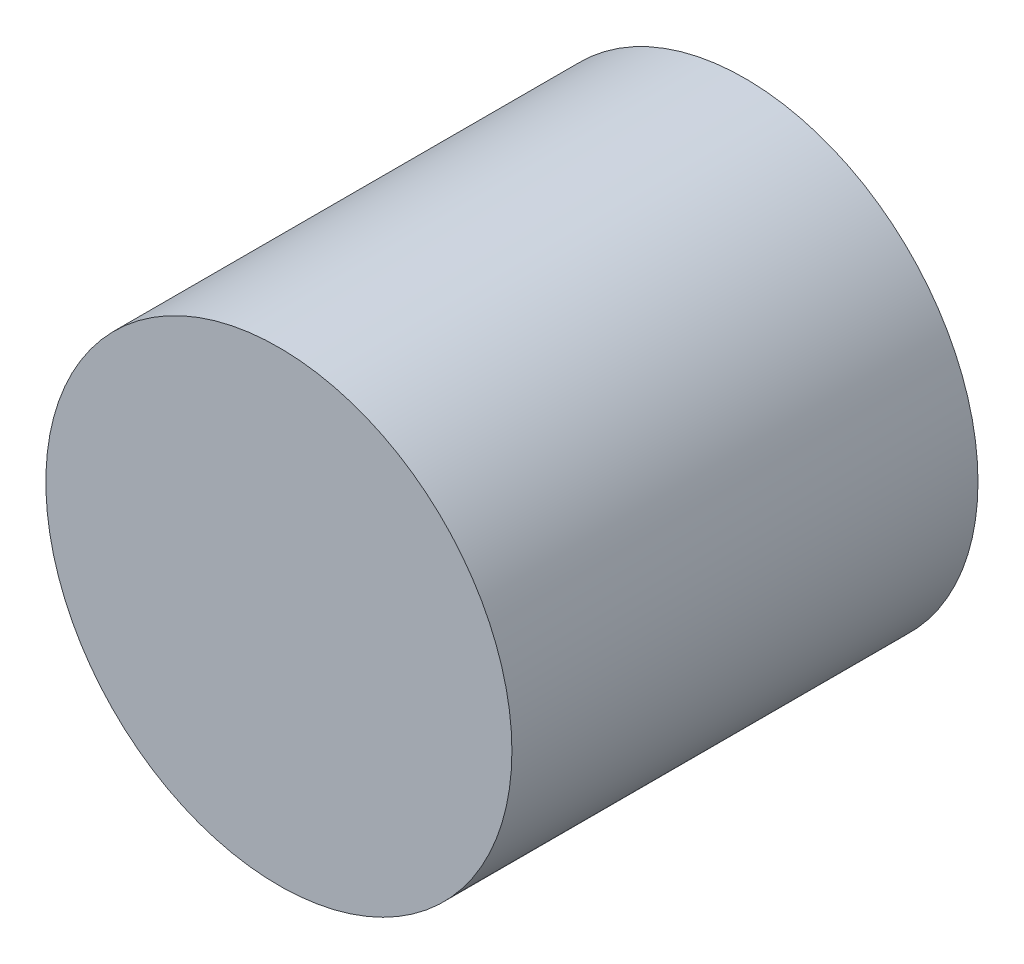
from build123d import *

# Parameters (mm, degrees)
SKETCH1_R           = 12.5
BOSS_EXTRUDE1_DEPTH = 25


with BuildPart() as part:
    # Sketch1 → Boss-Extrude1 (new body)
    with BuildSketch(Plane.XY):
        Circle(SKETCH1_R)
    extrude(amount=BOSS_EXTRUDE1_DEPTH)


solid = part.part
